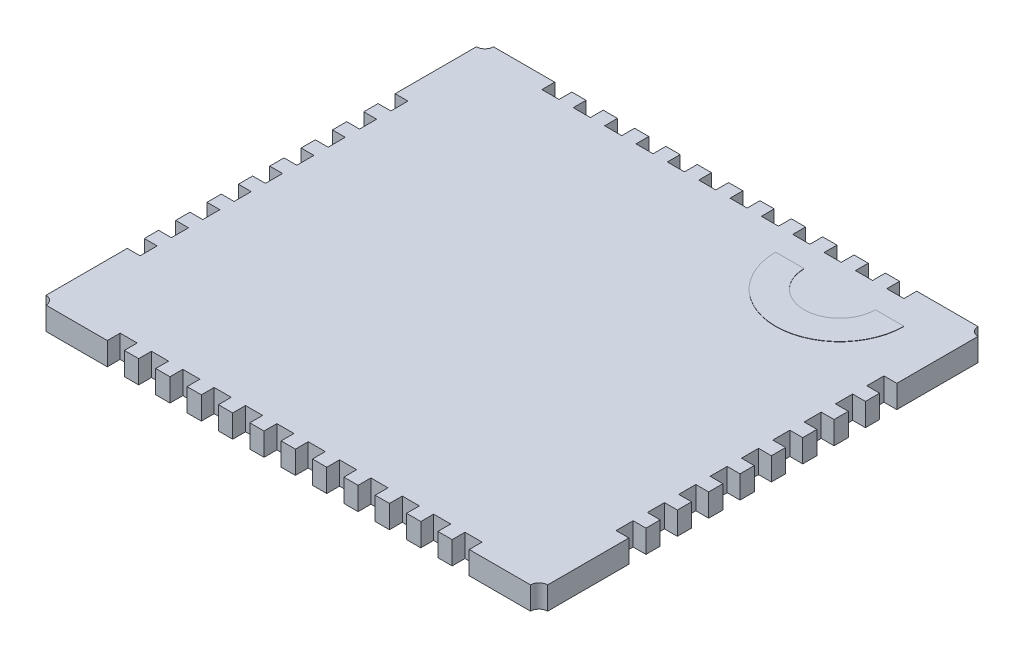
from build123d import *

# Parameters (mm, degrees)
BOSS_EXTRU_1_DEPTH = 0.8
BOSS_EXTRU_2_DEPTH = 0.01


with BuildPart() as part:
    # Esquisse1 → Boss.-Extru.1 (new body)
    with BuildSketch(Plane(origin=(0, 0, 0), x_dir=(1, 0, 0), z_dir=(0, 1, 0))):
        with BuildLine():
            Line((-8.281226766, 3.982713755), (-8.881226766, 3.982713755))
            Line((-8.881226766, 3.982713755), (-8.881226766, 4.432713755))
            Line((-8.881226766, 4.432713755), (-9.381226766, 4.432713755))
            Line((-9.381226766, 4.432713755), (-9.381226766, 3.982713755))
            Line((-9.381226766, 3.982713755), (-9.981226766, 3.982713755))
            Line((-9.981226766, 3.982713755), (-9.981226766, 4.432713755))
            Line((-9.981226766, 4.432713755), (-12.131226766, 4.432713755))
            ThreePointArc((-12.131226766, 4.432713755), (-12.219094731, 4.22058172), (-12.431226766, 4.132713755))
            Line((-12.431226766, 4.132713755), (-12.431226766, 1.282713755))
            Line((-12.431226766, 1.282713755), (-11.981226766, 1.282713755))
            Line((-11.981226766, 1.282713755), (-11.981226766, 0.682713755))
            Line((-11.981226766, 0.682713755), (-12.431226766, 0.682713755))
            Line((-12.431226766, 0.682713755), (-12.431226766, 0.182713755))
            Line((-12.431226766, 0.182713755), (-11.981226766, 0.182713755))
            Line((-11.981226766, 0.182713755), (-11.981226766, -0.417286245))
            Line((-11.981226766, -0.417286245), (-12.431226766, -0.417286245))
            Line((-12.431226766, -0.417286245), (-12.431226766, -0.917286245))
            Line((-12.431226766, -0.917286245), (-11.981226766, -0.917286245))
            Line((-11.981226766, -0.917286245), (-11.981226766, -1.517286245))
            Line((-11.981226766, -1.517286245), (-12.431226766, -1.517286245))
            Line((-12.431226766, -1.517286245), (-12.431226766, -2.017286245))
            Line((-12.431226766, -2.017286245), (-11.981226766, -2.017286245))
            Line((-11.981226766, -2.017286245), (-11.981226766, -2.617286245))
            Line((-11.981226766, -2.617286245), (-12.431226766, -2.617286245))
            Line((-12.431226766, -2.617286245), (-12.431226766, -3.117286245))
            Line((-12.431226766, -3.117286245), (-11.981226766, -3.117286245))
            Line((-11.981226766, -3.117286245), (-11.981226766, -3.717286245))
            Line((-11.981226766, -3.717286245), (-12.431226766, -3.717286245))
            Line((-12.431226766, -3.717286245), (-12.431226766, -4.217286245))
            Line((-12.431226766, -4.217286245), (-11.981226766, -4.217286245))
            Line((-11.981226766, -4.217286245), (-11.981226766, -4.817286245))
            Line((-11.981226766, -4.817286245), (-12.431226766, -4.817286245))
            Line((-12.431226766, -4.817286245), (-12.431226766, -5.317286245))
            Line((-12.431226766, -5.317286245), (-11.981226766, -5.317286245))
            Line((-11.981226766, -5.317286245), (-11.981226766, -5.917286245))
            Line((-11.981226766, -5.917286245), (-12.431226766, -5.917286245))
            Line((-12.431226766, -5.917286245), (-12.431226766, -6.417286245))
            Line((-12.431226766, -6.417286245), (-11.981226766, -6.417286245))
            Line((-11.981226766, -6.417286245), (-11.981226766, -7.017286245))
            Line((-11.981226766, -7.017286245), (-12.431226766, -7.017286245))
            Line((-12.431226766, -7.017286245), (-12.431226766, -7.517286245))
            Line((-12.431226766, -7.517286245), (-11.981226766, -7.517286245))
            Line((-11.981226766, -7.517286245), (-11.981226766, -8.117286245))
            Line((-11.981226766, -8.117286245), (-12.431226766, -8.117286245))
            Line((-12.431226766, -8.117286245), (-12.431226766, -10.967286245))
            ThreePointArc((-12.431226766, -10.967286245), (-12.219094731, -11.055154211), (-12.131226766, -11.267286245))
            Line((-12.131226766, -11.267286245), (-9.981226766, -11.267286245))
            Line((-9.981226766, -11.267286245), (-9.981226766, -10.817286245))
            Line((-9.981226766, -10.817286245), (-9.381226766, -10.817286245))
            Line((-9.381226766, -10.817286245), (-9.381226766, -11.267286245))
            Line((-9.381226766, -11.267286245), (-8.881226766, -11.267286245))
            Line((-8.881226766, -11.267286245), (-8.881226766, -10.817286245))
            Line((-8.881226766, -10.817286245), (-8.281226766, -10.817286245))
            Line((-8.281226766, -10.817286245), (-8.281226766, -11.267286245))
            Line((-8.281226766, -11.267286245), (-7.781226766, -11.267286245))
            Line((-7.781226766, -11.267286245), (-7.781226766, -10.817286245))
            Line((-7.781226766, -10.817286245), (-7.181226766, -10.817286245))
            Line((-7.181226766, -10.817286245), (-7.181226766, -11.267286245))
            Line((-7.181226766, -11.267286245), (-6.681226766, -11.267286245))
            Line((-6.681226766, -11.267286245), (-6.681226766, -10.817286245))
            Line((-6.681226766, -10.817286245), (-6.081226766, -10.817286245))
            Line((-6.081226766, -10.817286245), (-6.081226766, -11.267286245))
            Line((-6.081226766, -11.267286245), (-5.581226766, -11.267286245))
            Line((-5.581226766, -11.267286245), (-5.581226766, -10.817286245))
            Line((-5.581226766, -10.817286245), (-4.981226766, -10.817286245))
            Line((-4.981226766, -10.817286245), (-4.981226766, -11.267286245))
            Line((-4.981226766, -11.267286245), (-4.481226766, -11.267286245))
            Line((-4.481226766, -11.267286245), (-4.481226766, -10.817286245))
            Line((-4.481226766, -10.817286245), (-3.881226766, -10.817286245))
            Line((-3.881226766, -10.817286245), (-3.881226766, -11.267286245))
            Line((-3.881226766, -11.267286245), (-3.381226766, -11.267286245))
            Line((-3.381226766, -11.267286245), (-3.381226766, -10.817286245))
            Line((-3.381226766, -10.817286245), (-2.781226766, -10.817286245))
            Line((-2.781226766, -10.817286245), (-2.781226766, -11.267286245))
            Line((-2.781226766, -11.267286245), (-2.281226766, -11.267286245))
            Line((-2.281226766, -11.267286245), (-2.281226766, -10.817286245))
            Line((-2.281226766, -10.817286245), (-1.681226766, -10.817286245))
            Line((-1.681226766, -10.817286245), (-1.681226766, -11.267286245))
            Line((-1.681226766, -11.267286245), (-1.181226766, -11.267286245))
            Line((-1.181226766, -11.267286245), (-1.181226766, -10.817286245))
            Line((-1.181226766, -10.817286245), (-0.581226766, -10.817286245))
            Line((-0.581226766, -10.817286245), (-0.581226766, -11.267286245))
            Line((-0.581226766, -11.267286245), (-0.081226766, -11.267286245))
            Line((-0.081226766, -11.267286245), (-0.081226766, -10.817286245))
            Line((-0.081226766, -10.817286245), (0.518773234, -10.817286245))
            Line((0.518773234, -10.817286245), (0.518773234, -11.267286245))
            Line((0.518773234, -11.267286245), (1.018773234, -11.267286245))
            Line((1.018773234, -11.267286245), (1.018773234, -10.817286245))
            Line((1.018773234, -10.817286245), (1.618773234, -10.817286245))
            Line((1.618773234, -10.817286245), (1.618773234, -11.267286245))
            Line((1.618773234, -11.267286245), (2.118773234, -11.267286245))
            Line((2.118773234, -11.267286245), (2.118773234, -10.817286245))
            Line((2.118773234, -10.817286245), (2.718773234, -10.817286245))
            Line((2.718773234, -10.817286245), (2.718773234, -11.267286245))
            Line((2.718773234, -11.267286245), (4.868773234, -11.267286245))
            ThreePointArc((4.868773234, -11.267286245), (4.9566412, -11.055154211), (5.168773234, -10.967286245))
            Line((5.168773234, -10.967286245), (5.168773234, -8.117286245))
            Line((5.168773234, -8.117286245), (4.718773234, -8.117286245))
            Line((4.718773234, -8.117286245), (4.718773234, -7.517286245))
            Line((4.718773234, -7.517286245), (5.168773234, -7.517286245))
            Line((5.168773234, -7.517286245), (5.168773234, -7.017286245))
            Line((5.168773234, -7.017286245), (4.718773234, -7.017286245))
            Line((4.718773234, -7.017286245), (4.718773234, -6.417286245))
            Line((4.718773234, -6.417286245), (5.168773234, -6.417286245))
            Line((5.168773234, -6.417286245), (5.168773234, -5.917286245))
            Line((5.168773234, -5.917286245), (4.718773234, -5.917286245))
            Line((4.718773234, -5.917286245), (4.718773234, -5.317286245))
            Line((4.718773234, -5.317286245), (5.168773234, -5.317286245))
            Line((5.168773234, -5.317286245), (5.168773234, -4.817286245))
            Line((5.168773234, -4.817286245), (4.718773234, -4.817286245))
            Line((4.718773234, -4.817286245), (4.718773234, -4.217286245))
            Line((4.718773234, -4.217286245), (5.168773234, -4.217286245))
            Line((5.168773234, -4.217286245), (5.168773234, -3.717286245))
            Line((5.168773234, -3.717286245), (4.718773234, -3.717286245))
            Line((4.718773234, -3.717286245), (4.718773234, -3.117286245))
            Line((4.718773234, -3.117286245), (5.168773234, -3.117286245))
            Line((5.168773234, -3.117286245), (5.168773234, -2.617286245))
            Line((5.168773234, -2.617286245), (4.718773234, -2.617286245))
            Line((4.718773234, -2.617286245), (4.718773234, -2.017286245))
            Line((4.718773234, -2.017286245), (5.168773234, -2.017286245))
            Line((5.168773234, -2.017286245), (5.168773234, -1.517286245))
            Line((5.168773234, -1.517286245), (4.718773234, -1.517286245))
            Line((4.718773234, -1.517286245), (4.718773234, -0.917286245))
            Line((4.718773234, -0.917286245), (5.168773234, -0.917286245))
            Line((5.168773234, -0.917286245), (5.168773234, -0.417286245))
            Line((5.168773234, -0.417286245), (4.718773234, -0.417286245))
            Line((4.718773234, -0.417286245), (4.718773234, 0.182713755))
            Line((4.718773234, 0.182713755), (5.168773234, 0.182713755))
            Line((5.168773234, 0.182713755), (5.168773234, 0.682713755))
            Line((5.168773234, 0.682713755), (4.718773234, 0.682713755))
            Line((4.718773234, 0.682713755), (4.718773234, 1.282713755))
            Line((4.718773234, 1.282713755), (5.168773234, 1.282713755))
            Line((5.168773234, 1.282713755), (5.168773234, 4.132713755))
            ThreePointArc((5.168773234, 4.132713755), (4.9566412, 4.22058172), (4.868773234, 4.432713755))
            Line((4.868773234, 4.432713755), (2.718773234, 4.432713755))
            Line((2.718773234, 4.432713755), (2.718773234, 3.982713755))
            Line((2.718773234, 3.982713755), (2.118773234, 3.982713755))
            Line((2.118773234, 3.982713755), (2.118773234, 4.432713755))
            Line((2.118773234, 4.432713755), (1.618773234, 4.432713755))
            Line((1.618773234, 4.432713755), (1.618773234, 3.982713755))
            Line((1.618773234, 3.982713755), (1.018773234, 3.982713755))
            Line((1.018773234, 3.982713755), (1.018773234, 4.432713755))
            Line((1.018773234, 4.432713755), (0.518773234, 4.432713755))
            Line((0.518773234, 4.432713755), (0.518773234, 3.982713755))
            Line((0.518773234, 3.982713755), (-0.081226766, 3.982713755))
            Line((-0.081226766, 3.982713755), (-0.081226766, 4.432713755))
            Line((-0.081226766, 4.432713755), (-0.581226766, 4.432713755))
            Line((-0.581226766, 4.432713755), (-0.581226766, 3.982713755))
            Line((-0.581226766, 3.982713755), (-1.181226766, 3.982713755))
            Line((-1.181226766, 3.982713755), (-1.181226766, 4.432713755))
            Line((-1.181226766, 4.432713755), (-1.681226766, 4.432713755))
            Line((-1.681226766, 4.432713755), (-1.681226766, 3.982713755))
            Line((-1.681226766, 3.982713755), (-2.281226766, 3.982713755))
            Line((-2.281226766, 3.982713755), (-2.281226766, 4.432713755))
            Line((-2.281226766, 4.432713755), (-2.781226766, 4.432713755))
            Line((-2.781226766, 4.432713755), (-2.781226766, 3.982713755))
            Line((-2.781226766, 3.982713755), (-3.381226766, 3.982713755))
            Line((-3.381226766, 3.982713755), (-3.381226766, 4.432713755))
            Line((-3.381226766, 4.432713755), (-3.881226766, 4.432713755))
            Line((-3.881226766, 4.432713755), (-3.881226766, 3.982713755))
            Line((-3.881226766, 3.982713755), (-4.481226766, 3.982713755))
            Line((-4.481226766, 3.982713755), (-4.481226766, 4.432713755))
            Line((-4.481226766, 4.432713755), (-4.981226766, 4.432713755))
            Line((-4.981226766, 4.432713755), (-4.981226766, 3.982713755))
            Line((-4.981226766, 3.982713755), (-5.581226766, 3.982713755))
            Line((-5.581226766, 3.982713755), (-5.581226766, 4.432713755))
            Line((-5.581226766, 4.432713755), (-6.081226766, 4.432713755))
            Line((-6.081226766, 4.432713755), (-6.081226766, 3.982713755))
            Line((-6.081226766, 3.982713755), (-6.681226766, 3.982713755))
            Line((-6.681226766, 3.982713755), (-6.681226766, 4.432713755))
            Line((-6.681226766, 4.432713755), (-7.181226766, 4.432713755))
            Line((-7.181226766, 4.432713755), (-7.181226766, 3.982713755))
            Line((-7.181226766, 3.982713755), (-7.781226766, 3.982713755))
            Line((-7.781226766, 3.982713755), (-7.781226766, 4.432713755))
            Line((-7.781226766, 4.432713755), (-8.281226766, 4.432713755))
            Line((-8.281226766, 4.432713755), (-8.281226766, 3.982713755))
        make_face()
    extrude(amount=BOSS_EXTRU_1_DEPTH)

    # Esquisse2 → Boss.-Extru.2 (add)
    with BuildSketch(Plane(origin=(0, 0.8, 0), x_dir=(1, 0, 0), z_dir=(0, 1, 0))):
        with BuildLine():
            Line((-0.931226766, 3.132713755), (0.068773234, 3.132713755))
            ThreePointArc((0.068773234, 3.132713755), (1.318773234, 1.882713755), (2.568773234, 3.132713755))
            Line((2.568773234, 3.132713755), (3.568773234, 3.132713755))
            ThreePointArc((3.568773234, 3.132713755), (1.318773234, 0.882713755), (-0.931226766, 3.132713755))
        make_face()
    extrude(amount=BOSS_EXTRU_2_DEPTH)


solid = part.part
